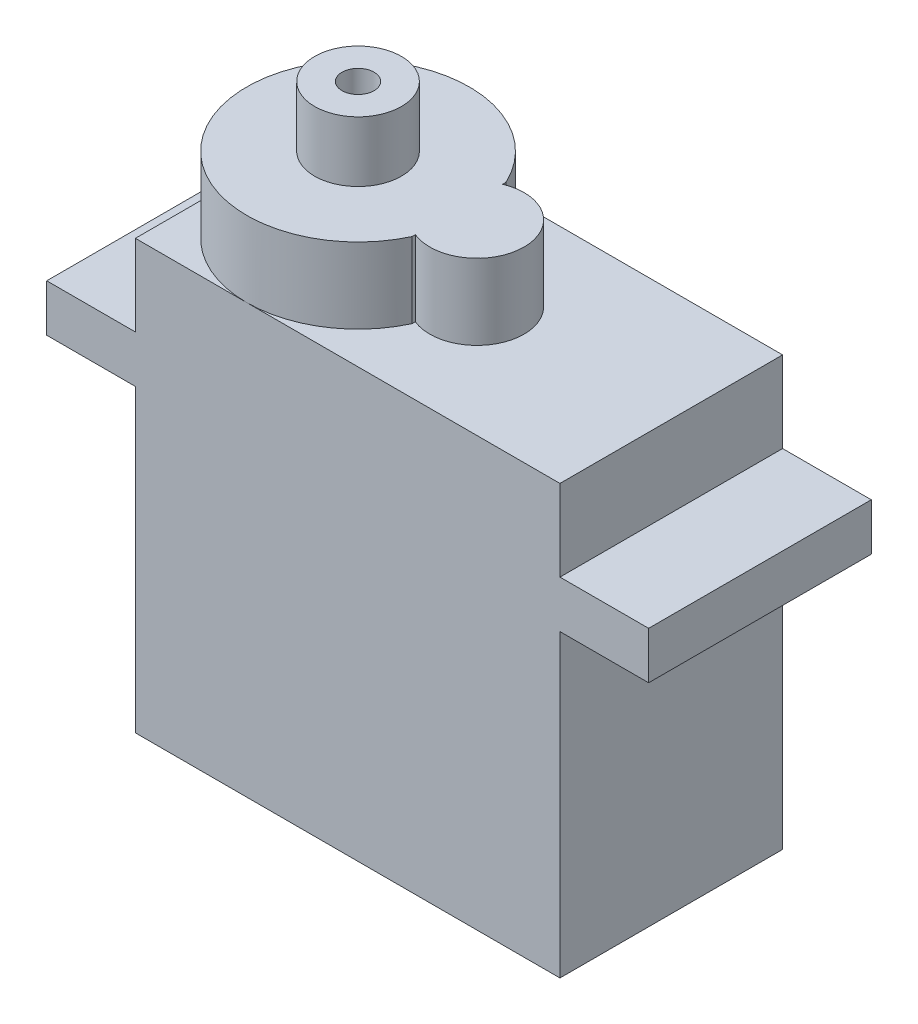
from build123d import *

# Parameters (mm, degrees)
CROQUIS1_W              = 4.7
CROQUIS1_H              = 2.5
CROQUIS1_W_2            = 22.5
CROQUIS1_H_2            = 15.9
SALIENTE_EXTRUIR1_DEPTH = 11.8
SALIENTE_EXTRUIR2_DEPTH = 4
SALIENTE_EXTRUIR3_DEPTH = 3.2


with BuildPart() as part:
    # Croquis1 → Saliente-Extruir1 (new body)
    with BuildSketch(Plane.XY):
        with Locations((-13.6, 5.8)):
            Rectangle(CROQUIS1_W, CROQUIS1_H)
        Polygon((-11.25, 7.05), (-11.25, 4.55), (11.25, 4.55), (11.25, 7.05), (11.25, 11.35), (-11.25, 11.35), align=None)
        with Locations((0, -3.4)):
            Rectangle(CROQUIS1_W_2, CROQUIS1_H_2)
        with Locations((13.6, 5.8)):
            Rectangle(CROQUIS1_W, CROQUIS1_H)
    extrude(amount=SALIENTE_EXTRUIR1_DEPTH)

    # Croquis3 → Saliente-Extruir2 (add)
    with BuildSketch(Plane(origin=(0, 11.35, 0), x_dir=(1, 0, 0), z_dir=(0, 1, 0))):
        with BuildLine():
            ThreePointArc((0.066666667, -3.561256273), (0.427903311, -4.705917367), (0.55, -5.9))
            Line((0.55, -5.9), (3.45, -5.9))
            ThreePointArc((3.45, -5.9), (2.371560176, -3.84350622), (0.066666667, -3.561256273))
        make_face()
        with BuildLine():
            Line((3.45, -5.9), (0.55, -5.9))
            ThreePointArc((0.55, -5.9), (0.427903311, -7.094082633), (0.066666667, -8.238743727))
            ThreePointArc((0.066666667, -8.238743727), (2.371560176, -7.95649378), (3.45, -5.9))
        make_face()
        with BuildLine():
            Line((0, -8.212466216), (0, -5.9))
            Line((0, -5.9), (-1.55, -5.9))
            ThreePointArc((-1.55, -5.9), (-1.126655966, -7.291941091), (0, -8.212466216))
        make_face()
        with BuildLine():
            Line((-1.55, -5.9), (0, -5.9))
            Line((0, -5.9), (0, -3.587533784))
            ThreePointArc((0, -3.587533784), (-1.126655966, -4.508058909), (-1.55, -5.9))
        make_face()
        with BuildLine():
            ThreePointArc((0.066666667, -8.238743727), (0.427903311, -7.094082633), (0.55, -5.9))
            Line((0.55, -5.9), (0, -5.9))
            Line((0, -5.9), (0, -8.212466216))
            ThreePointArc((0, -8.212466216), (0.033239178, -8.225843846), (0.066666667, -8.238743727))
        make_face()
        with BuildLine():
            Line((0, -5.9), (0.55, -5.9))
            ThreePointArc((0.55, -5.9), (0.427903311, -4.705917367), (0.066666667, -3.561256273))
            ThreePointArc((0.066666667, -3.561256273), (0.033239178, -3.574156154), (0, -3.587533784))
            Line((0, -3.587533784), (0, -5.9))
        make_face()
        with BuildLine():
            ThreePointArc((0, -8.212466216), (-1.126655966, -7.291941091), (-1.55, -5.9))
            Line((-1.55, -5.9), (-11.25, -5.9))
            ThreePointArc((-11.25, -5.9), (-6.62377392, -11.660859311), (0, -8.387468593))
            Line((0, -8.387468593), (0, -8.212466216))
        make_face()
        with BuildLine():
            Line((-11.25, -5.9), (-1.55, -5.9))
            ThreePointArc((-1.55, -5.9), (-1.126655966, -4.508058909), (0, -3.587533784))
            Line((0, -3.587533784), (0, -3.412531407))
            ThreePointArc((0, -3.412531407), (-6.62377392, -0.139140689), (-11.25, -5.9))
        make_face()
    extrude(amount=SALIENTE_EXTRUIR2_DEPTH)

    # Croquis4 → Saliente-Extruir3 (add)
    with BuildSketch(Plane(origin=(0, 15.35, 0), x_dir=(1, 0, 0), z_dir=(0, 1, 0))):
        with BuildLine():
            ThreePointArc((-6.2, -5.9), (-5.35, -5.05), (-4.5, -5.9))
            Line((-4.5, -5.9), (-3.05, -5.9))
            ThreePointArc((-3.05, -5.9), (-5.35, -3.6), (-7.65, -5.9))
            Line((-7.65, -5.9), (-6.2, -5.9))
        make_face()
        with BuildLine():
            Line((-3.05, -5.9), (-4.5, -5.9))
            ThreePointArc((-4.5, -5.9), (-5.35, -6.75), (-6.2, -5.9))
            Line((-6.2, -5.9), (-7.65, -5.9))
            ThreePointArc((-7.65, -5.9), (-5.35, -8.2), (-3.05, -5.9))
        make_face()
    extrude(amount=SALIENTE_EXTRUIR3_DEPTH)


solid = part.part
